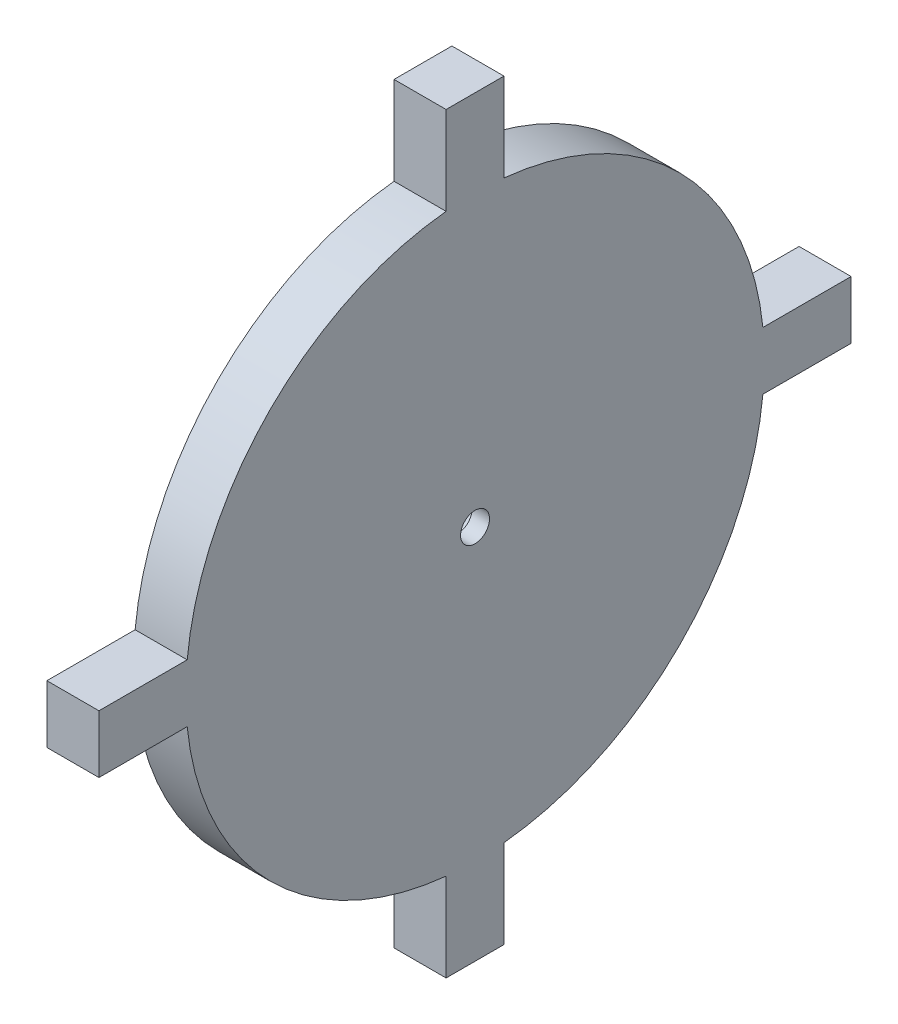
from build123d import *

# Parameters (mm, degrees)
SKETCH1_R           = 3.175
BOSS_EXTRUDE1_DEPTH = 11.43
SKETCH2_R           = 9.776464607
CUT_EXTRUDE1_DEPTH  = 7.62


with BuildPart() as part:
    # Sketch1 → Boss-Extrude1 (new body)
    with BuildSketch(Plane(origin=(0, 0, 0), x_dir=(0, 0, -1), z_dir=(1, 0, 0))):
        with BuildLine():
            Line((6.35, 82.55), (-6.35, 82.55))
            Line((-6.35, 82.55), (-6.35, 63.181702256))
            ThreePointArc((-6.35, 63.181702256), (-44.901280605, 44.901280605), (-63.181702256, 6.35))
            Line((-63.181702256, 6.35), (-82.55, 6.35))
            Line((-82.55, 6.35), (-82.55, -6.35))
            Line((-82.55, -6.35), (-63.181702256, -6.35))
            ThreePointArc((-63.181702256, -6.35), (-44.901280605, -44.901280605), (-6.35, -63.181702256))
            Line((-6.35, -63.181702256), (-6.35, -82.55))
            Line((-6.35, -82.55), (6.35, -82.55))
            Line((6.35, -82.55), (6.35, -63.181702256))
            ThreePointArc((6.35, -63.181702256), (44.901280605, -44.901280605), (63.181702256, -6.35))
            Line((63.181702256, -6.35), (82.55, -6.35))
            Line((82.55, -6.35), (82.55, 6.35))
            Line((82.55, 6.35), (63.181702256, 6.35))
            ThreePointArc((63.181702256, 6.35), (44.901280605, 44.901280605), (6.35, 63.181702256))
            Line((6.35, 63.181702256), (6.35, 82.55))
        make_face()
        Circle(SKETCH1_R, mode=Mode.SUBTRACT)
    extrude(amount=BOSS_EXTRUDE1_DEPTH)

    # Sketch2 → Cut-Extrude1 (cut)
    with BuildSketch(Plane.ZY):
        Circle(SKETCH2_R)
    extrude(amount=-CUT_EXTRUDE1_DEPTH, mode=Mode.SUBTRACT)


solid = part.part
